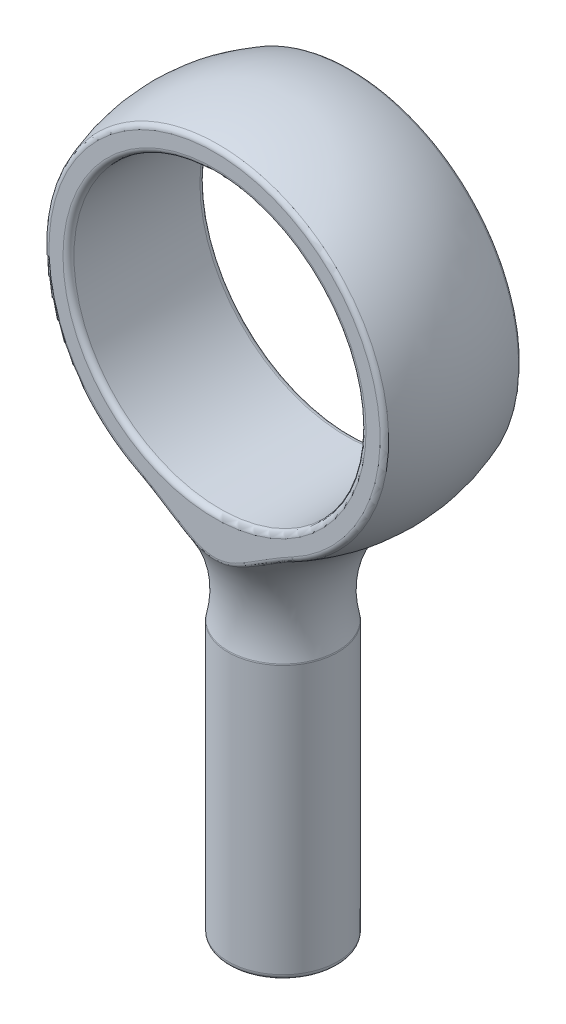
from build123d import *

# Parameters (mm, degrees)
CUT_EXTRUDE1_DEPTH      = 10
CUT_EXTRUDE1_DEPTH_BACK = 10
CUT_EXTRUDE2_DEPTH      = 10
CUT_EXTRUDE2_DEPTH_BACK = 10
SKETCH4_R               = 4
FILLET1_R               = 0.15
SKETCH5_R               = 1
CUT_EXTRUDE3_DEPTH      = 5
CHAMFER1_SIZE           = 0.05


with BuildPart() as part:
    # Sketch2 → Revolve1 (revolve)
    with BuildSketch(Plane.XY):
        with BuildLine():
            Line((0, 5), (0, -15))
            Line((0, -15), (-1.5, -15))
            Line((-1.5, -15), (-1.5, -7.5))
            ThreePointArc((-1.5, -7.5), (-1.630201198, -5.615116851), (-2.807502077, -4.137382275))
            ThreePointArc((-2.807502077, -4.137382275), (-4.779482784, 1.468517726), (0, 5))
        make_face()
    revolve(axis=Axis((0, 5, 0), (0, -1, 0)))

    # Sketch3 → Cut-Extrude1 (cut, two sides: drawn at the far end of the back side and taken through both)
    with BuildSketch(Plane(origin=(0, 0, 0), x_dir=(0, 0, -1), z_dir=(1, 0, 0)).offset(-CUT_EXTRUDE1_DEPTH_BACK)):
        with BuildLine():
            Line((10.828047963, -19.615541135), (10.828047963, 7.663704163))
            Line((10.828047963, 7.663704163), (1.875, 7.663704163))
            Line((1.875, 7.663704163), (1.875, -5.252769588))
            ThreePointArc((1.875, -5.252769588), (2.106415246, -6.756298585), (2.779239779, -8.120651769))
            Line((2.779239779, -8.120651769), (10.828047963, -19.615541135))
        make_face()
        with BuildLine():
            Line((-2.779239779, -8.120651769), (-10.828047963, -19.615541135))
            Line((-10.828047963, -19.615541135), (-10.828047963, 7.663704163))
            Line((-10.828047963, 7.663704163), (-1.875, 7.663704163))
            Line((-1.875, 7.663704163), (-1.875, -5.252769588))
            ThreePointArc((-1.875, -5.252769588), (-2.106415246, -6.756298585), (-2.779239779, -8.120651769))
        make_face()
    extrude(amount=CUT_EXTRUDE1_DEPTH + CUT_EXTRUDE1_DEPTH_BACK, mode=Mode.SUBTRACT)

    # Sketch4 → Cut-Extrude2 (cut, two sides: drawn at the far end of the back side and taken through both)
    with BuildSketch(Plane(origin=(0, 0, -1.875), x_dir=(-1, 0, 0), z_dir=(0, 0, -1)).offset(-CUT_EXTRUDE2_DEPTH_BACK)):
        Circle(SKETCH4_R)
    extrude(amount=CUT_EXTRUDE2_DEPTH + CUT_EXTRUDE2_DEPTH_BACK, mode=Mode.SUBTRACT)

    # Fillet1
    fillet1_edges = [part.edges().sort_by_distance(p)[0] for p in [
        (4, 0, 1.875),
        (4, 0, -1.875),
        (0, 4.635124054, 1.875),
        (0, 4.635124054, -1.875),
        (1.5, -15, 0),
        (1.5, -7.5, 0),
        (1.5, -7.5, 0),
        (1.5, -7.5, 0),
    ]]
    fillet(fillet1_edges, radius=FILLET1_R)

    # Sketch5 → Cut-Extrude3 (cut)
    with BuildSketch(Plane.XZ.offset(15)):
        Circle(SKETCH5_R)
    extrude(amount=-CUT_EXTRUDE3_DEPTH, mode=Mode.SUBTRACT)

    # Chamfer1
    chamfer1_edges = [part.edges().sort_by_distance(p)[0] for p in [
        (-1, -15, 0),
    ]]
    chamfer(chamfer1_edges, length=CHAMFER1_SIZE)


solid = part.part
